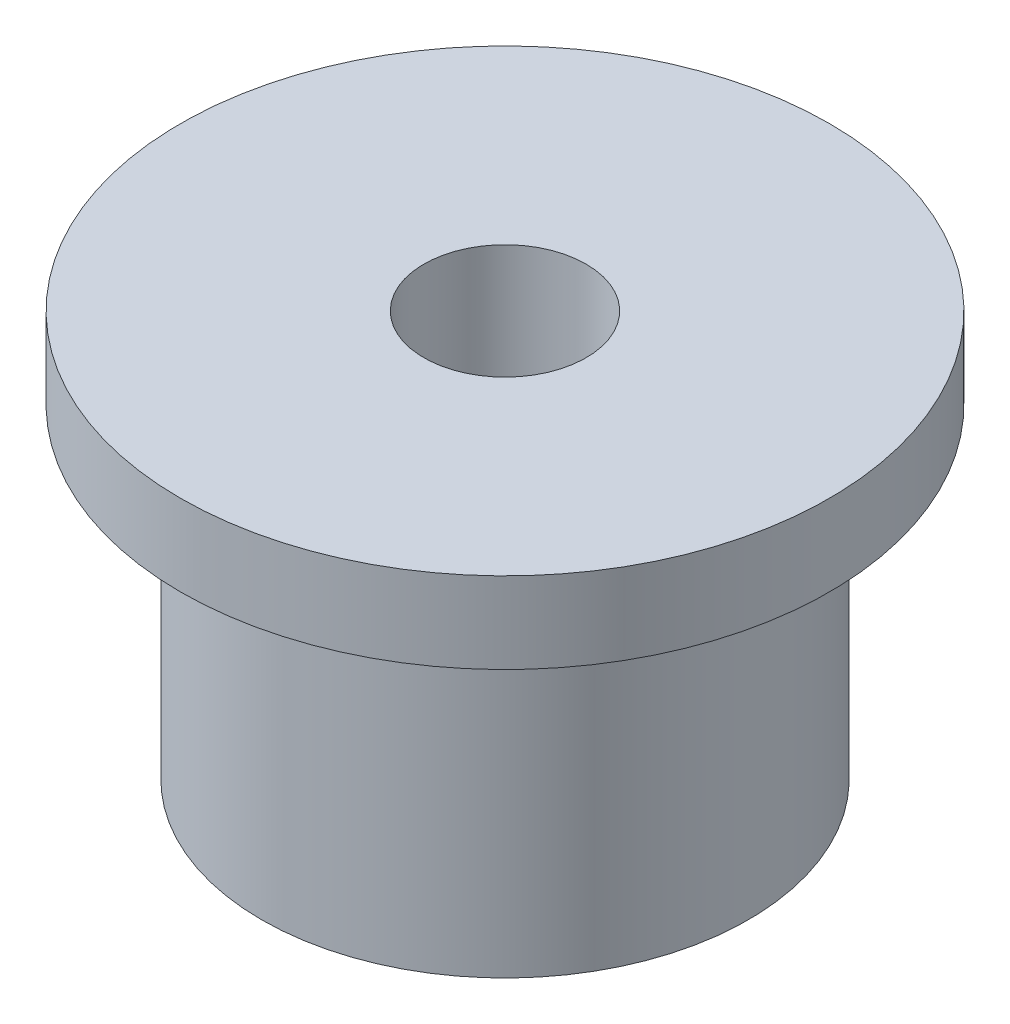
from build123d import *


with BuildPart() as part:
    # Sketch1 → Revolve1 (revolve)
    with BuildSketch(Plane.XY):
        Polygon((25, 0), (25, 125), (100, 125), (100, 100), (75, 100), (75, 0), align=None)
    revolve(axis=Axis((0, 0, 0), (0, 1, 0)))


solid = part.part
